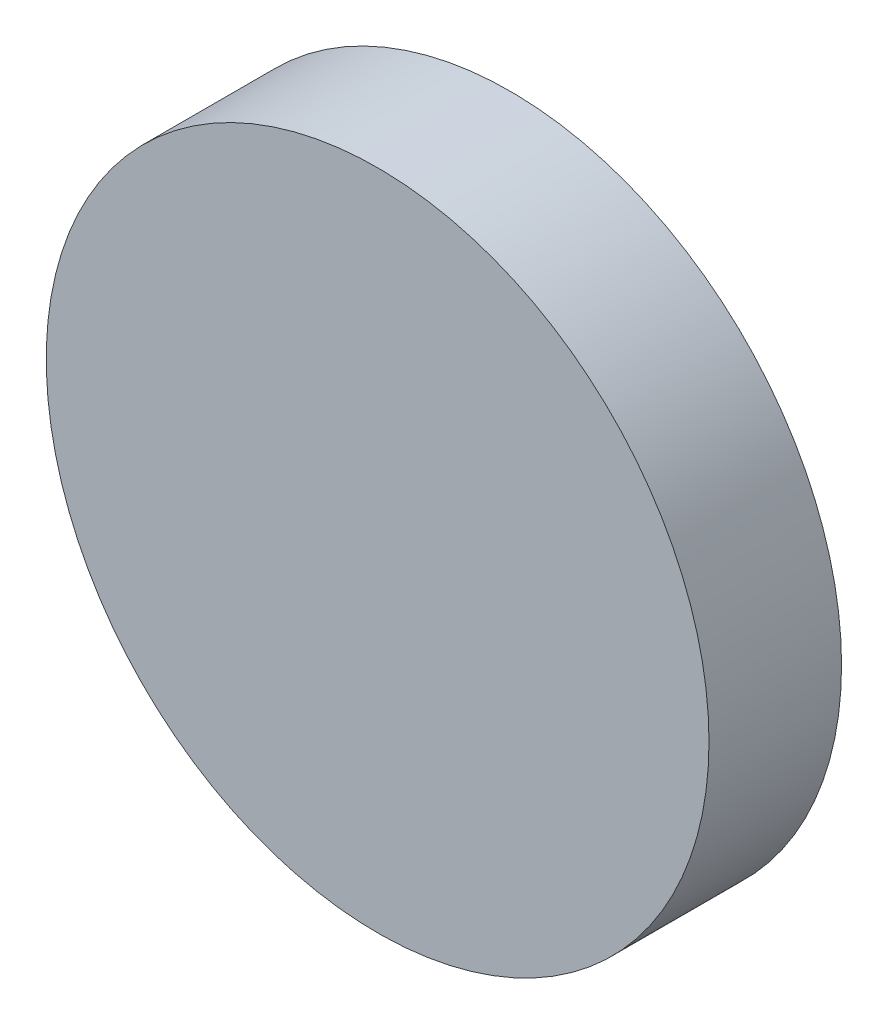
from build123d import *

# Parameters (mm, degrees)
ESBO_O1_R                = 100
RESSALTO_EXTRUS_O1_DEPTH = 40


with BuildPart() as part:
    # Esboço1 → Ressalto-extrusão1 (new body)
    with BuildSketch(Plane.XY):
        Circle(ESBO_O1_R)
    extrude(amount=RESSALTO_EXTRUS_O1_DEPTH)


solid = part.part
